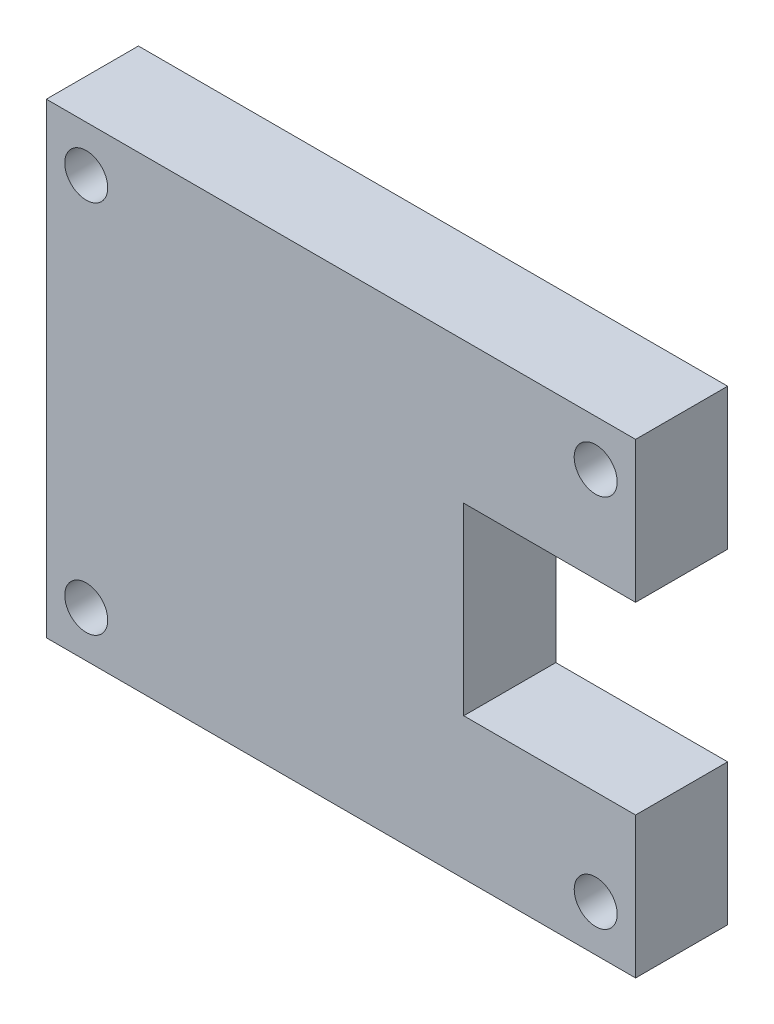
from build123d import *

# Parameters (mm, degrees)
ESQUISSE1_W             = 48
ESQUISSE1_H             = 38
BOSS_EXTRU_1_DEPTH      = 7.5
ESQUISSE2_R             = 1.75
ENL_V_MAT_EXTRU_1_DEPTH = 7.5
ESQUISSE4_W             = 14
ESQUISSE4_H             = 15
ENL_V_MAT_EXTRU_2_DEPTH = 7.5


with BuildPart() as part:
    # Esquisse1 → Boss.-Extru.1 (new body)
    with BuildSketch(Plane.XY):
        Rectangle(ESQUISSE1_W, ESQUISSE1_H)
    extrude(amount=BOSS_EXTRU_1_DEPTH)

    # Esquisse2 → Enlèv. mat.-Extru.1 (cut)
    with BuildSketch(Plane.XY.offset(7.5)):
        with Locations((20.75, 15.25)):
            Circle(ESQUISSE2_R)
        with Locations((-20.75, 15.25)):
            Circle(ESQUISSE2_R)
        with Locations((20.75, -15.25)):
            Circle(ESQUISSE2_R)
        with Locations((-20.75, -15.25)):
            Circle(ESQUISSE2_R)
    extrude(amount=-ENL_V_MAT_EXTRU_1_DEPTH, mode=Mode.SUBTRACT)

    # Esquisse4 → Enlèv. mat.-Extru.2 (cut)
    with BuildSketch(Plane.XY.offset(7.5)):
        with Locations((17, 0)):
            Rectangle(ESQUISSE4_W, ESQUISSE4_H)
    extrude(amount=-ENL_V_MAT_EXTRU_2_DEPTH, mode=Mode.SUBTRACT)


solid = part.part
